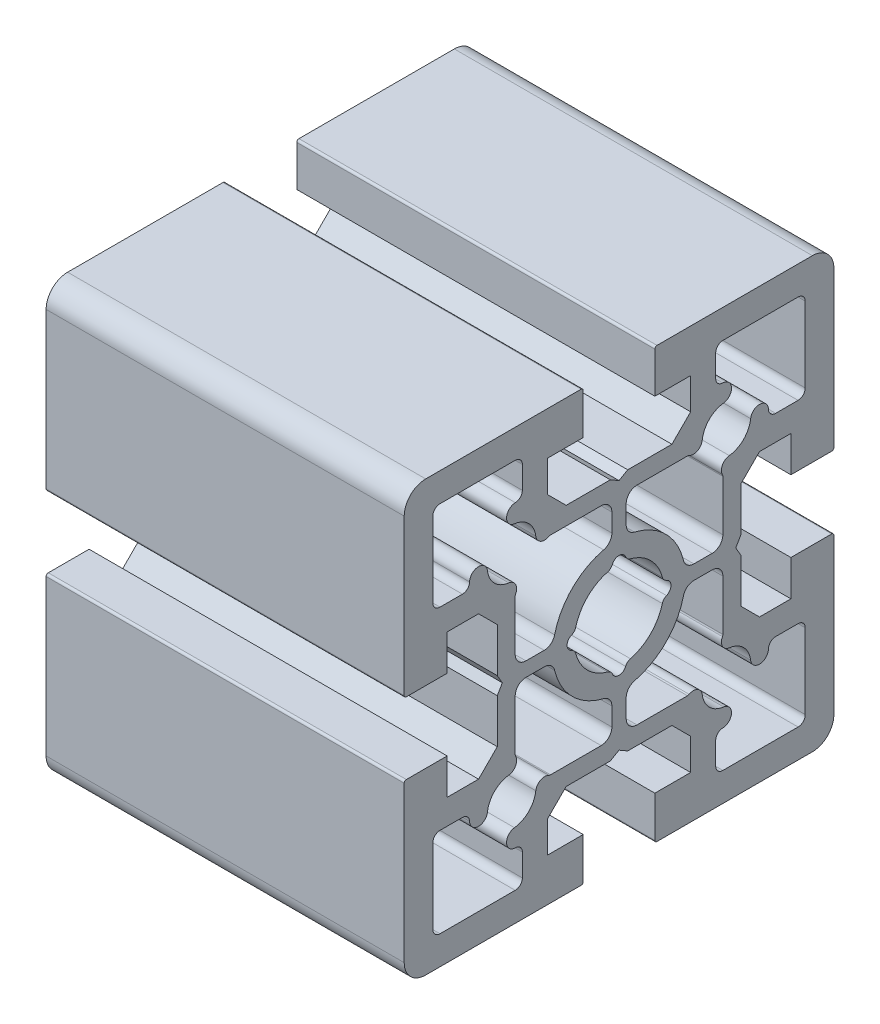
from build123d import *

# Parameters (mm, degrees)
STRUCTURAL_MEMBER1_DEPTH = 50


with BuildPart() as part:
    # Sketch12 → Structural Member1 (new body)
    with BuildSketch(Plane.YZ.offset(-25)):
        with BuildLine():
            Line((-30, 27), (-30, 5.3))
            ThreePointArc((-30, 5.3), (-29.912132034, 5.087867966), (-29.7, 5))
            Line((-29.7, 5), (-24, 5))
            Line((-24, 5), (-24, 10))
            Line((-24, 10), (-19.616652, 10))
            Line((-19.616652, 10), (-17, 7.383348))
            Line((-17, 7.383348), (-17, 1.212435))
            Line((-17, 1.212435), (-16.3, 0))
            Line((-16.3, 0), (-17, -1.212436))
            Line((-17, -1.212436), (-17, -7.383348))
            Line((-17, -7.383348), (-19.616652, -10))
            Line((-19.616652, -10), (-24, -10))
            Line((-24, -10), (-24, -5))
            Line((-24, -5), (-29.7, -5))
            ThreePointArc((-29.7, -5), (-29.912132034, -5.087867966), (-30, -5.3))
            Line((-30, -5.3), (-30, -27))
            ThreePointArc((-30, -27), (-29.121320344, -29.121320344), (-27, -30))
            Line((-27, -30), (-5.3, -30))
            ThreePointArc((-5.3, -30), (-5.087867966, -29.912132034), (-5, -29.7))
            Line((-5, -29.7), (-5, -24))
            Line((-5, -24), (-10, -24))
            Line((-10, -24), (-10, -19.616652))
            Line((-10, -19.616652), (-7.383348, -17))
            Line((-7.383348, -17), (-1.212436, -17))
            Line((-1.212436, -17), (0, -16.3))
            Line((0, -16.3), (1.212435, -17))
            Line((1.212435, -17), (7.383348, -17))
            Line((7.383348, -17), (10, -19.616652))
            Line((10, -19.616652), (10, -24))
            Line((10, -24), (5, -24))
            Line((5, -24), (5, -29.7))
            ThreePointArc((5, -29.7), (5.087867966, -29.912132034), (5.3, -30))
            Line((5.3, -30), (27, -30))
            ThreePointArc((27, -30), (29.121320344, -29.121320344), (30, -27))
            Line((30, -27), (30, -5.3))
            ThreePointArc((30, -5.3), (29.912132034, -5.087867966), (29.7, -5))
            Line((29.7, -5), (24, -5))
            Line((24, -5), (24, -10))
            Line((24, -10), (19.616652, -10))
            Line((19.616652, -10), (17, -7.383348))
            Line((17, -7.383348), (17, -1.212436))
            Line((17, -1.212436), (16.3, 0))
            Line((16.3, 0), (17, 1.212435))
            Line((17, 1.212435), (17, 7.383348))
            Line((17, 7.383348), (19.616652, 10))
            Line((19.616652, 10), (24, 10))
            Line((24, 10), (24, 5))
            Line((24, 5), (29.7, 5))
            ThreePointArc((29.7, 5), (29.912132034, 5.087867966), (30, 5.3))
            Line((30, 5.3), (30, 27))
            ThreePointArc((30, 27), (29.121320344, 29.121320344), (27, 30))
            Line((27, 30), (5.3, 30))
            ThreePointArc((5.3, 30), (5.087867966, 29.912132034), (5, 29.7))
            Line((5, 29.7), (5, 24))
            Line((5, 24), (10, 24))
            Line((10, 24), (10, 19.616652))
            Line((10, 19.616652), (7.383348, 17))
            Line((7.383348, 17), (1.212435, 17))
            Line((1.212435, 17), (0, 16.3))
            Line((0, 16.3), (-1.212436, 17))
            Line((-1.212436, 17), (-7.383348, 17))
            Line((-7.383348, 17), (-10, 19.616652))
            Line((-10, 19.616652), (-10, 24))
            Line((-10, 24), (-5, 24))
            Line((-5, 24), (-5, 29.7))
            ThreePointArc((-5, 29.7), (-5.087867966, 29.912132034), (-5.3, 30))
            Line((-5.3, 30), (-27, 30))
            ThreePointArc((-27, 30), (-29.121320344, 29.121320344), (-30, 27))
        make_face()
        with BuildLine():
            Line((1.000000108, -10.455262108), (1.000000108, -13.000000108))
            ThreePointArc((1.000000108, -13.000000108), (1.439339937, -14.06066028), (2.500000108, -14.500000108))
            Line((2.500000108, -14.500000108), (9.557752108, -14.500000108))
            ThreePointArc((9.557752108, -14.500000108), (9.679117874, -14.48504686), (9.793224411, -14.441081569))
            ThreePointArc((9.793224411, -14.441081569), (10.960915645, -14.435973392), (11.623328671, -15.397606324))
            ThreePointArc((11.623328671, -15.397606324), (12.595837052, -17.404163164), (14.602393892, -18.376671546))
            ThreePointArc((14.602393892, -18.376671546), (15.704722433, -19.679164405), (14.480540108, -20.867858434))
            ThreePointArc((14.480540108, -20.867858434), (13.786046335, -21.167476271), (13.500000108, -21.867669106))
            Line((13.500000108, -21.867669106), (13.500000108, -25.000000108))
            ThreePointArc((13.500000108, -25.000000108), (13.792893327, -25.707106889), (14.500000108, -26.000000108))
            Line((14.500000108, -26.000000108), (25.000000108, -26.000000108))
            ThreePointArc((25.000000108, -26.000000108), (25.707106889, -25.707106889), (26.000000108, -25.000000108))
            Line((26.000000108, -25.000000108), (26.000000108, -14.500000108))
            ThreePointArc((26.000000108, -14.500000108), (25.707106889, -13.792893327), (25.000000108, -13.500000108))
            Line((25.000000108, -13.500000108), (21.867668108, -13.500000108))
            ThreePointArc((21.867668108, -13.500000108), (21.167475272, -13.786046334), (20.867857434, -14.480540108))
            ThreePointArc((20.867857434, -14.480540108), (19.679163717, -15.704722418), (18.376671136, -14.602393903))
            ThreePointArc((18.376671136, -14.602393903), (17.404163021, -12.595837196), (15.397606314, -11.623329081))
            ThreePointArc((15.397606314, -11.623329081), (14.435973302, -10.960916473), (14.441081569, -9.793225411))
            ThreePointArc((14.441081569, -9.793225411), (14.485046966, -9.67911845), (14.500000108, -9.557752236))
            Line((14.500000108, -9.557752236), (14.500000108, -2.500000108))
            ThreePointArc((14.500000108, -2.500000108), (14.06066028, -1.439339937), (13.000000108, -1.000000108))
            Line((13.000000108, -1.000000108), (10.455262108, -1.000000108))
            ThreePointArc((10.455262108, -1.000000108), (9.526083906, -1.322448467), (8.996388227, -2.151162872))
            ThreePointArc((8.996388227, -2.151162872), (6.540737834, -6.540737834), (2.151162872, -8.996388227))
            ThreePointArc((2.151162872, -8.996388227), (1.322448467, -9.526083906), (1.000000108, -10.455262108))
        make_face(mode=Mode.SUBTRACT)
        with BuildLine():
            Line((1.000000127, 12.99999997), (1.000000127, 10.45526197))
            ThreePointArc((1.000000127, 10.45526197), (1.322448486, 9.526083767), (2.15116289, 8.996388088))
            ThreePointArc((2.15116289, 8.996388088), (6.540737834, 6.54073765), (8.996388149, 2.151162637))
            ThreePointArc((8.996388149, 2.151162637), (9.526083828, 1.322448232), (10.45526203, 0.999999873))
            Line((10.45526203, 0.999999873), (13.00000003, 0.999999873))
            ThreePointArc((13.00000003, 0.999999873), (14.060660202, 1.439339701), (14.50000003, 2.499999873))
            Line((14.50000003, 2.499999873), (14.50000003, 9.557751873))
            ThreePointArc((14.50000003, 9.557751873), (14.485046782, 9.679117638), (14.441081491, 9.793224176))
            ThreePointArc((14.441081491, 9.793224176), (14.435973283, 10.960915512), (15.397606343, 11.623328532))
            ThreePointArc((15.397606343, 11.623328532), (17.40416312, 12.59583685), (18.376671154, 14.602393764))
            ThreePointArc((18.376671154, 14.602393764), (19.679163736, 15.70472228), (20.867857453, 14.48053997))
            ThreePointArc((20.867857453, 14.48053997), (21.167475291, 13.786046195), (21.867668127, 13.49999997))
            Line((21.867668127, 13.49999997), (25.000000127, 13.49999997))
            ThreePointArc((25.000000127, 13.49999997), (25.707106908, 13.792893188), (26.000000127, 14.49999997))
            Line((26.000000127, 14.49999997), (26.000000127, 24.99999997))
            ThreePointArc((26.000000127, 24.99999997), (25.707106908, 25.707106751), (25.000000127, 25.99999997))
            Line((25.000000127, 25.99999997), (14.500000127, 25.99999997))
            ThreePointArc((14.500000127, 25.99999997), (13.792893346, 25.707106751), (13.500000127, 24.99999997))
            Line((13.500000127, 24.99999997), (13.500000127, 21.86766797))
            ThreePointArc((13.500000127, 21.86766797), (13.786046353, 21.167475133), (14.480540127, 20.867857295))
            ThreePointArc((14.480540127, 20.867857295), (15.704722437, 19.679163579), (14.602393921, 18.376670997))
            ThreePointArc((14.602393921, 18.376670997), (12.595837151, 17.404162819), (11.62332869, 15.397606186))
            ThreePointArc((11.62332869, 15.397606186), (10.960915664, 14.435973254), (9.79322443, 14.44108143))
            ThreePointArc((9.79322443, 14.44108143), (9.679117892, 14.485046721), (9.557752127, 14.49999997))
            Line((9.557752127, 14.49999997), (2.500000127, 14.49999997))
            ThreePointArc((2.500000127, 14.49999997), (1.439339955, 14.060660141), (1.000000127, 12.99999997))
        make_face(mode=Mode.SUBTRACT)
        with BuildLine():
            Line((-26, 25), (-26, 14.5))
            ThreePointArc((-26, 14.5), (-25.707106781, 13.792893219), (-25, 13.5))
            Line((-25, 13.5), (-21.867669, 13.5))
            ThreePointArc((-21.867669, 13.5), (-21.167476164, 13.786046226), (-20.867858326, 14.48054))
            ThreePointArc((-20.867858326, 14.48054), (-19.679164297, 15.704722325), (-18.376671437, 14.602393784))
            ThreePointArc((-18.376671437, 14.602393784), (-17.404163056, 12.595836944), (-15.397606216, 11.623328563))
            ThreePointArc((-15.397606216, 11.623328563), (-14.435973284, 10.960915537), (-14.44108146, 9.793224303))
            ThreePointArc((-14.44108146, 9.793224303), (-14.485046751, 9.679117765), (-14.5, 9.557752))
            Line((-14.5, 9.557752), (-14.5, 2.5))
            ThreePointArc((-14.5, 2.5), (-14.060660172, 1.439339828), (-13, 1))
            Line((-13, 1), (-10.455262, 1))
            ThreePointArc((-10.455262, 1), (-9.526083797, 1.322448359), (-8.996388119, 2.151162763))
            ThreePointArc((-8.996388119, 2.151162763), (-6.540737714, 6.54073777), (-2.151162686, 8.996388137))
            ThreePointArc((-2.151162686, 8.996388137), (-1.32244747, 9.526084843), (-0.999999922, 10.455264635))
            Line((-0.999999922, 10.455264635), (-0.999999922, 13.000000019))
            ThreePointArc((-0.999999922, 13.000000019), (-1.439339784, 14.060660206), (-2.5, 14.5))
            Line((-2.5, 14.5), (-9.557753, 14.5))
            ThreePointArc((-9.557753, 14.5), (-9.679118765, 14.485046751), (-9.793225303, 14.44108146))
            ThreePointArc((-9.793225303, 14.44108146), (-10.960916365, 14.435973194), (-11.623328972, 15.397606206))
            ThreePointArc((-11.623328972, 15.397606206), (-12.595838174, 17.404163999), (-14.602396846, 18.376671387))
            ThreePointArc((-14.602396846, 18.376671387), (-15.704722235, 19.679165144), (-14.48054, 20.867857326))
            ThreePointArc((-14.48054, 20.867857326), (-13.786045616, 21.167475786), (-13.5, 21.867669743))
            Line((-13.5, 21.867669743), (-13.5, 25))
            ThreePointArc((-13.5, 25), (-13.792893219, 25.707106781), (-14.5, 26))
            Line((-14.5, 26), (-25, 26))
            ThreePointArc((-25, 26), (-25.707106781, 25.707106781), (-26, 25))
        make_face(mode=Mode.SUBTRACT)
        with BuildLine():
            Line((-26, -14.5), (-26, -25))
            ThreePointArc((-26, -25), (-25.707106781, -25.707106781), (-25, -26))
            Line((-25, -26), (-14.5, -26))
            ThreePointArc((-14.5, -26), (-13.792893219, -25.707106781), (-13.5, -25))
            Line((-13.5, -25), (-13.5, -21.867669))
            ThreePointArc((-13.5, -21.867669), (-13.786046226, -21.167476164), (-14.48054, -20.867858326))
            ThreePointArc((-14.48054, -20.867858326), (-15.704722325, -19.679164297), (-14.602393784, -18.376671437))
            ThreePointArc((-14.602393784, -18.376671437), (-12.595837007, -17.404163119), (-11.623328972, -15.397606206))
            ThreePointArc((-11.623328972, -15.397606206), (-10.960916365, -14.435973194), (-9.793225303, -14.44108146))
            ThreePointArc((-9.793225303, -14.44108146), (-9.679118765, -14.485046751), (-9.557753, -14.5))
            Line((-9.557753, -14.5), (-2.5, -14.5))
            ThreePointArc((-2.5, -14.5), (-1.439339828, -14.060660172), (-1, -13))
            Line((-1, -13), (-1, -10.455262))
            ThreePointArc((-1, -10.455262), (-1.322448359, -9.526083797), (-2.151162763, -8.996388119))
            ThreePointArc((-2.151162763, -8.996388119), (-6.540737742, -6.540737742), (-8.996388119, -2.151162763))
            ThreePointArc((-8.996388119, -2.151162763), (-9.526083797, -1.322448359), (-10.455262, -1))
            Line((-10.455262, -1), (-13, -1))
            ThreePointArc((-13, -1), (-14.060660172, -1.439339828), (-14.5, -2.5))
            Line((-14.5, -2.5), (-14.5, -9.557753))
            ThreePointArc((-14.5, -9.557753), (-14.485046751, -9.679118765), (-14.44108146, -9.793225303))
            ThreePointArc((-14.44108146, -9.793225303), (-14.435973194, -10.960916365), (-15.397606206, -11.623328972))
            ThreePointArc((-15.397606206, -11.623328972), (-17.404162976, -12.595837151), (-18.376671437, -14.602393784))
            ThreePointArc((-18.376671437, -14.602393784), (-19.679164297, -15.704722325), (-20.867858326, -14.48054))
            ThreePointArc((-20.867858326, -14.48054), (-21.167476164, -13.786046226), (-21.867669, -13.5))
            Line((-21.867669, -13.5), (-25, -13.5))
            ThreePointArc((-25, -13.5), (-25.707106781, -13.792893219), (-26, -14.5))
        make_face(mode=Mode.SUBTRACT)
        with BuildLine():
            ThreePointArc((-6.629999892, 0.924986392), (-6.25787188, 1.190955856), (-6.043103335, 1.594804201))
            ThreePointArc((-6.043103335, 1.594804201), (-4.41941729, 4.41941729), (-1.594804201, 6.043103335))
            ThreePointArc((-1.594804201, 6.043103335), (-1.190955856, 6.25787188), (-0.924986392, 6.629999892))
            ThreePointArc((-0.924986392, 6.629999892), (-0.000122524, 7.249999884), (0.924893371, 6.630226734))
            ThreePointArc((0.924893371, 6.630226734), (1.190885901, 6.257891025), (1.594901392, 6.043048316))
            ThreePointArc((1.594901392, 6.043048316), (4.419458321, 4.419376444), (6.043103552, 1.594804201))
            ThreePointArc((6.043103552, 1.594804201), (6.257872026, 1.190955915), (6.629999924, 0.92498644))
            ThreePointArc((6.629999924, 0.92498644), (7.249999924, -6e-08), (6.629999924, -0.92498656))
            ThreePointArc((6.629999924, -0.92498656), (6.257871912, -1.190956024), (6.043103368, -1.594804369))
            ThreePointArc((6.043103368, -1.594804369), (4.419417342, -4.419417343), (1.594804368, -6.043103368))
            ThreePointArc((1.594804368, -6.043103368), (1.190956711, -6.257869034), (0.924987314, -6.629994687))
            ThreePointArc((0.924987314, -6.629994687), (2.248e-06, -7.249999959), (-0.924986352, -6.629999959))
            ThreePointArc((-0.924986352, -6.629999959), (-1.190955817, -6.257871947), (-1.594804161, -6.043103403))
            ThreePointArc((-1.594804161, -6.043103403), (-4.419417235, -4.419417422), (-6.043103335, -1.594804417))
            ThreePointArc((-6.043103335, -1.594804417), (-6.25787188, -1.190956073), (-6.629999892, -0.924986608))
            ThreePointArc((-6.629999892, -0.924986608), (-7.249999892, -1.08e-07), (-6.629999892, 0.924986392))
        make_face(mode=Mode.SUBTRACT)
    extrude(amount=STRUCTURAL_MEMBER1_DEPTH)


solid = part.part
